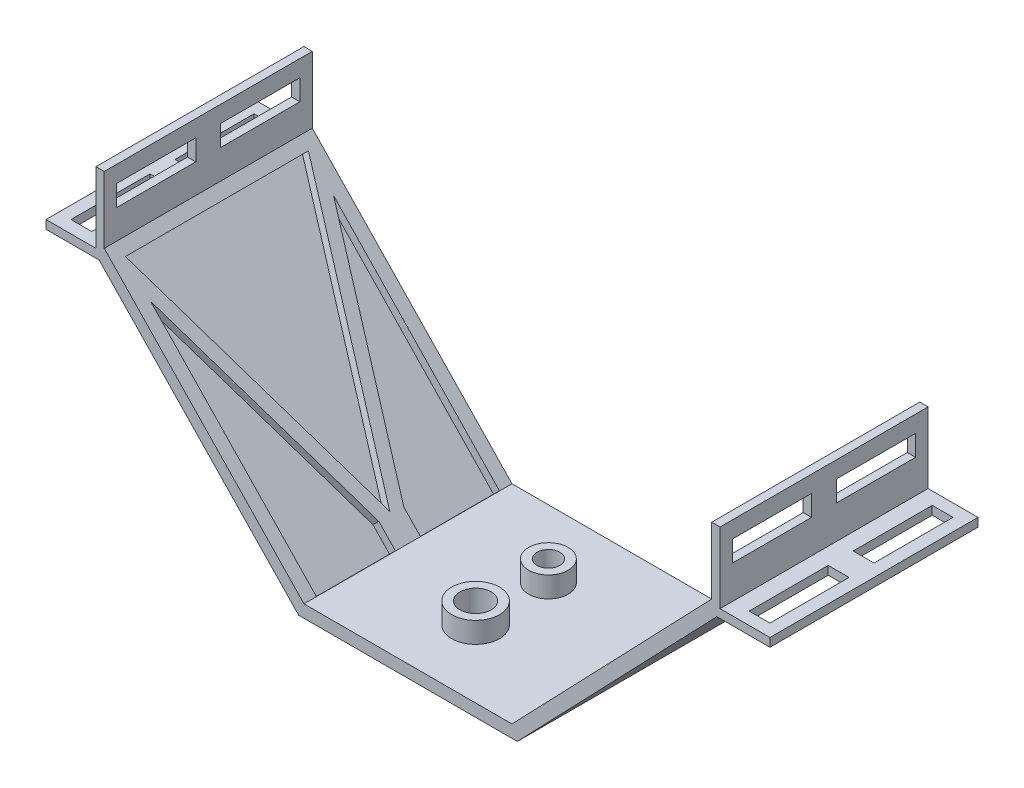
from build123d import *

# Parameters (mm, degrees)
SKETCH1_W               = 50
SKETCH1_H               = 50
SKETCH1_R               = 3.75
SKETCH1_R_2             = 2.75
BOSS_EXTRUDE1_DEPTH     = 3
BOSS_EXTRUDE2_DEPTH     = 50
CUT_EXTRUDE2_DEPTH      = 2
SKETCH10_W              = 50
SKETCH10_H              = 2.047418662
BOSS_EXTRUDE6_DEPTH     = 2
SKETCH11_W              = 5
SKETCH11_H              = 19
CUT_EXTRUDE4_DEPTH      = 4
SKETCH12_W              = 2
SKETCH12_H              = 50
BOSS_EXTRUDE7_DEPTH     = 10
SKETCH13_W              = 19
SKETCH13_H              = 5
CUT_EXTRUDE5_DEPTH      = 10
SKETCH14_R              = 5.75
SKETCH14_R_2            = 3.75
SKETCH14_R_3            = 4.75
SKETCH14_R_4            = 2.75
BOSS_EXTRUDE8_DEPTH     = 5
SKETCH15_W              = 50
SKETCH15_H              = 3
CUT_EXTRUDE6_DEPTH      = 161
CUT_EXTRUDE6_DEPTH_BACK = 15


with BuildPart() as part:
    # Sketch1 → Boss-Extrude1 (new body)
    with BuildSketch(Plane(origin=(0, 0, 0), x_dir=(1, 0, 0), z_dir=(0, 1, 0))):
        with Locations((0, 8.75)):
            Rectangle(SKETCH1_W, SKETCH1_H)
        Circle(SKETCH1_R, mode=Mode.SUBTRACT)
        with Locations((0, 17.5)):
            Circle(SKETCH1_R_2, mode=Mode.SUBTRACT)
    extrude(amount=BOSS_EXTRUDE1_DEPTH)

    # Sketch2 → Boss-Extrude2 (add)
    with BuildSketch(Plane.XY.offset(16.25)):
        Polygon((-25, 0), (-26.278653628, 0), (-74.233131713, 49.952581338), (-85, 49.952581338), (-85, 52), (-75, 52), (-75, 62), (-73, 62), (-73, 53), (-25, 3), align=None)
    boss_extrude2 = extrude(amount=-BOSS_EXTRUDE2_DEPTH)

    # Sketch3 → Cut-Extrude2 (cut)
    with BuildSketch(Plane(origin=(-11.511240633, -11.050791007, 0), x_dir=(0, 0, -1), z_dir=(0.721387321, 0.692531828, 0))):
        Polygon((-13.25, 85.788351472), (30.75, 85.788351472), (8.75, 25.788351472), align=None)
        Polygon((30.75, 77.073872213), (11.75, 25.255690395), (11.75, 19.477457668), (30.75, 19.477457668), (30.75, 22.897932802), align=None)
        Polygon((-13.25, 77.073872213), (-13.25, 19.477457668), (5.75, 19.477457668), (5.75, 25.255690395), align=None)
    cut_extrude2 = extrude(amount=-CUT_EXTRUDE2_DEPTH, mode=Mode.SUBTRACT)

    # Mirror1: Boss-Extrude2, Cut-Extrude2 across plane
    add(boss_extrude2.mirror(Plane(origin=(0, 0, 0), x_dir=(0, 0, 1), z_dir=(1, 0, 0))))
    add(cut_extrude2.mirror(Plane(origin=(0, 0, 0), x_dir=(0, 0, 1), z_dir=(1, 0, 0))), mode=Mode.SUBTRACT)

    # Sketch10 → Boss-Extrude6 (add)
    with BuildSketch(Plane(origin=(85, 0, 0), x_dir=(0, 0, -1), z_dir=(1, 0, 0))):
        with Locations((8.75, 50.976290669)):
            Rectangle(SKETCH10_W, SKETCH10_H)
    boss_extrude6 = extrude(amount=BOSS_EXTRUDE6_DEPTH)

    # Sketch11 → Cut-Extrude4 (cut)
    with BuildSketch(Plane(origin=(0, 49.952581338, 0), x_dir=(-1, 0, 0), z_dir=(0, -1, 0))):
        with Locations((-81.5, -3.75)):
            Rectangle(SKETCH11_W, SKETCH11_H)
        with Locations((-81.5, 21.25)):
            Rectangle(SKETCH11_W, SKETCH11_H)
    cut_extrude4 = extrude(amount=-CUT_EXTRUDE4_DEPTH, mode=Mode.SUBTRACT)

    # Mirror2: Boss-Extrude6, Cut-Extrude4 across plane
    add(boss_extrude6.mirror(Plane(origin=(0, 0, 0), x_dir=(0, 0, 1), z_dir=(1, 0, 0))))
    add(cut_extrude4.mirror(Plane(origin=(0, 0, 0), x_dir=(0, 0, 1), z_dir=(1, 0, 0))), mode=Mode.SUBTRACT)

    # Sketch12 → Boss-Extrude7 (add)
    with BuildSketch(Plane(origin=(0, 62, 0), x_dir=(1, 0, 0), z_dir=(0, 1, 0))):
        with Locations((74, 8.75)):
            Rectangle(SKETCH12_W, SKETCH12_H)
        with Locations((-74, 8.75)):
            Rectangle(SKETCH12_W, SKETCH12_H)
    extrude(amount=BOSS_EXTRUDE7_DEPTH)

    # Sketch13 → Cut-Extrude5 (cut)
    with BuildSketch(Plane.ZY.offset(-73)):
        with Locations((-21.25, 62.5)):
            Rectangle(SKETCH13_W, SKETCH13_H)
        with Locations((3.75, 62.5)):
            Rectangle(SKETCH13_W, SKETCH13_H)
    cut_extrude5 = extrude(amount=-CUT_EXTRUDE5_DEPTH, mode=Mode.SUBTRACT)

    # Mirror3: Cut-Extrude5 across plane
    add(cut_extrude5.mirror(Plane(origin=(0, 0, 0), x_dir=(0, 0, 1), z_dir=(1, 0, 0))), mode=Mode.SUBTRACT)

    # Sketch14 → Boss-Extrude8 (add)
    with BuildSketch(Plane(origin=(0, 3, 0), x_dir=(1, 0, 0), z_dir=(0, 1, 0))):
        Circle(SKETCH14_R)
        Circle(SKETCH14_R_2, mode=Mode.SUBTRACT)
        with Locations((0, 17.5)):
            Circle(SKETCH14_R_3)
        with Locations((0, 17.5)):
            Circle(SKETCH14_R_4, mode=Mode.SUBTRACT)
    extrude(amount=BOSS_EXTRUDE8_DEPTH)

    # Sketch15 → Cut-Extrude6 (cut, two sides)
    with BuildSketch(Plane.ZY.offset(-73)) as cut_extrude6_sk:
        with Locations((-8.75, 70.5)):
            Rectangle(SKETCH15_W, SKETCH15_H)
    extrude(amount=CUT_EXTRUDE6_DEPTH, mode=Mode.SUBTRACT)
    extrude(cut_extrude6_sk.sketch, amount=-CUT_EXTRUDE6_DEPTH_BACK, mode=Mode.SUBTRACT)


solid = part.part
